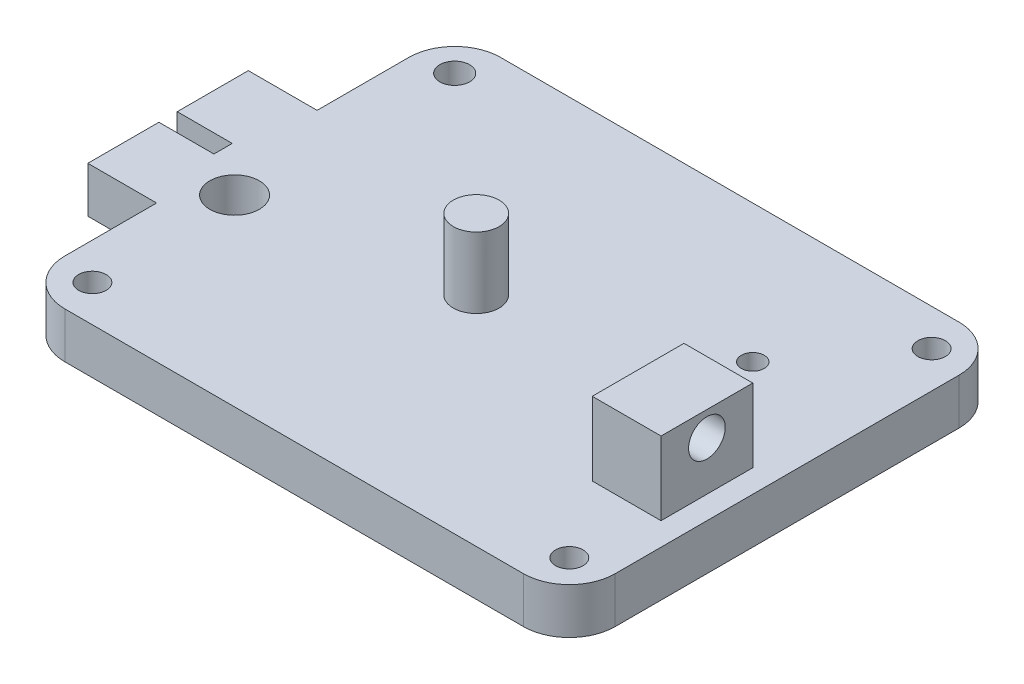
from build123d import *

# Parameters (mm, degrees)
SKETCH1_W           = 120
SKETCH1_H           = 95
BOSS_EXTRUDE1_DEPTH = 10
FILLET1_R           = 10
SKETCH3_R           = 5
BOSS_EXTRUDE3_DEPTH = 15.4
SKETCH4_W           = 15
SKETCH4_H           = 20
BOSS_EXTRUDE4_DEPTH = 16
SKETCH5_W           = 35
SKETCH5_H           = 10
BOSS_EXTRUDE5_DEPTH = 15
SKETCH6_W           = 12
SKETCH6_H           = 4
CUT_EXTRUDE1_DEPTH  = 11
SKETCH8_R           = 5.4
CUT_EXTRUDE3_DEPTH  = 11
SKETCH9_R           = 2.5
CUT_EXTRUDE4_DEPTH  = 11
CUT_EXTRUDE5_REACH  = 132
SKETCH10_R          = 4
SKETCH11_R          = 3.25
SKETCH11_R_2        = 3
CUT_EXTRUDE6_DEPTH  = 11
SKETCH12_R          = 2.5
SKETCH12_R_2        = 2.65
CUT_EXTRUDE7_DEPTH  = 5


with BuildPart() as part:
    # Sketch1 → Boss-Extrude1 (new body)
    with BuildSketch(Plane(origin=(0, 0, 0), x_dir=(1, 0, 0), z_dir=(0, 1, 0))):
        with Locations((60, 47.5)):
            Rectangle(SKETCH1_W, SKETCH1_H)
    extrude(amount=BOSS_EXTRUDE1_DEPTH)

    # Fillet1
    fillet1_edges = [part.edges().sort_by_distance(p)[0] for p in [
        (0, 5, -95),
        (120, 5, -95),
        (120, 5, 0),
        (0, 5, 0),
    ]]
    fillet(fillet1_edges, radius=FILLET1_R)

    # Sketch3 → Boss-Extrude3 (add)
    with BuildSketch(Plane(origin=(0, 10, 0), x_dir=(1, 0, 0), z_dir=(0, 1, 0))):
        with Locations((52.2, 47.5)):
            Circle(SKETCH3_R)
    extrude(amount=BOSS_EXTRUDE3_DEPTH)

    # Sketch4 → Boss-Extrude4 (add)
    with BuildSketch(Plane(origin=(0, 10, 0), x_dir=(1, 0, 0), z_dir=(0, 1, 0))):
        with Locations((107.5, 35)):
            Rectangle(SKETCH4_W, SKETCH4_H)
    extrude(amount=BOSS_EXTRUDE4_DEPTH)

    # Sketch5 → Boss-Extrude5 (add)
    with BuildSketch(Plane.ZY):
        with Locations((-47.5, 5)):
            Rectangle(SKETCH5_W, SKETCH5_H)
    extrude(amount=BOSS_EXTRUDE5_DEPTH)

    # Sketch6 → Cut-Extrude1 (cut, through all)
    with BuildSketch(Plane(origin=(0, 10, 0), x_dir=(1, 0, 0), z_dir=(0, 1, 0))):
        with Locations((-9, 47.5)):
            Rectangle(SKETCH6_W, SKETCH6_H)
    extrude(amount=-CUT_EXTRUDE1_DEPTH, mode=Mode.SUBTRACT)

    # Sketch8 → Cut-Extrude3 (cut, through all)
    with BuildSketch(Plane(origin=(0, 10, 0), x_dir=(1, 0, 0), z_dir=(0, 1, 0))):
        with Locations((7, 40)):
            Circle(SKETCH8_R)
    extrude(amount=-CUT_EXTRUDE3_DEPTH, mode=Mode.SUBTRACT)

    # Sketch9 → Cut-Extrude4 (cut, through all)
    with BuildSketch(Plane(origin=(0, 10, 0), x_dir=(1, 0, 0), z_dir=(0, 1, 0))):
        with Locations((95, 65)):
            Circle(SKETCH9_R)
    extrude(amount=-CUT_EXTRUDE4_DEPTH, mode=Mode.SUBTRACT)

    # Sketch10 → Cut-Extrude5 (cut, up to next)
    with BuildSketch(Plane(origin=(115, 0, 0), x_dir=(0, 0, -1), z_dir=(1, 0, 0)), mode=Mode.PRIVATE) as cut_extrude5_sk1:
        with Locations((35.000693392, 20.654678352)):
            Circle(SKETCH10_R)
    cut_extrude5_tool1 = extrude(cut_extrude5_sk1.sketch, amount=-CUT_EXTRUDE5_REACH, mode=Mode.PRIVATE) & part.part
    add(cut_extrude5_tool1.solids().sort_by_distance((115, 20.654678, -35.000693))[0], mode=Mode.SUBTRACT)

    # Sketch11 → Cut-Extrude6 (cut, through all)
    with BuildSketch(Plane(origin=(0, 10, 0), x_dir=(1, 0, 0), z_dir=(0, 1, 0))):
        with Locations((8, 87)):
            Circle(SKETCH11_R)
        with Locations((112, 87)):
            Circle(SKETCH11_R_2)
        with Locations((8, 8)):
            Circle(SKETCH11_R_2)
        with Locations((112, 8)):
            Circle(SKETCH11_R_2)
    extrude(amount=-CUT_EXTRUDE6_DEPTH, mode=Mode.SUBTRACT)

    # Sketch12 → Cut-Extrude7 (cut)
    with BuildSketch(Plane.XZ):
        with Locations((54.463993766, -37.5)):
            Circle(SKETCH12_R)
        with Locations((54.463993766, -57.5)):
            Circle(SKETCH12_R_2)
    extrude(amount=-CUT_EXTRUDE7_DEPTH, mode=Mode.SUBTRACT)


solid = part.part
